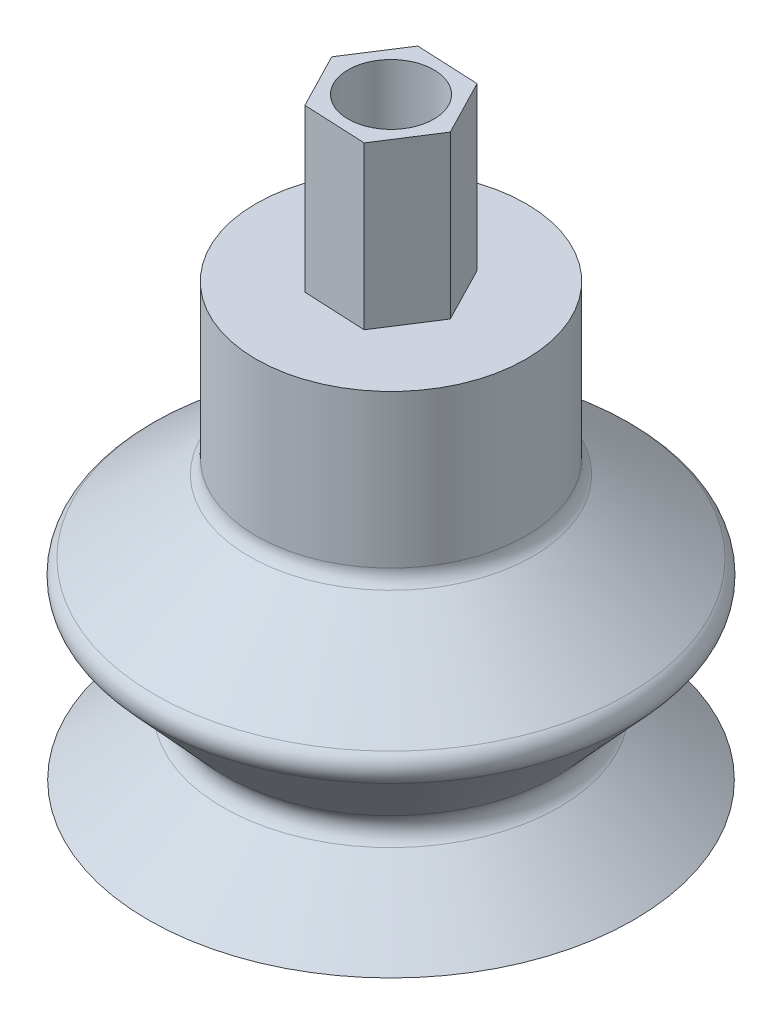
from build123d import *

# Parameters (mm, degrees)
CASCA1_T                 = -0.9
RESSALTO_EXTRUS_O1_DEPTH = 9
FILETE1_R                = 1
ESBO_O3_R                = 2.38125
CORTE_EXTRUS_O1_DEPTH    = 34.0000001
ESQUISSE1_R              = 6.732461852
ENL_V_MAT_EXTRU_1_DEPTH  = 9


with BuildPart() as part:
    # Esboço1 → Revolução1 (revolve)
    with BuildSketch(Plane.XY):
        Polygon((0, 0), (13.5, 0), (8.5, 4), (14, 10), (7.5, 15), (7.5, 24), (0, 24), align=None)
    revolve(axis=Axis((0, 24, 0), (0, -1, 0)))

    # Casca1
    casca1_openings = [part.faces().sort_by_distance(p)[0] for p in [
        (-13.5, 0, 0),
    ]]
    offset(amount=CASCA1_T, openings=casca1_openings, kind=Kind.INTERSECTION)

    # Esboço2 → Ressalto-extrusão1 (add)
    with BuildSketch(Plane(origin=(0, 24, 0), x_dir=(1, 0, 0), z_dir=(0, 1, 0))):
        Polygon((2.496763598, 3.885808136), (-2.11682676, 4.105164771), (-4.613590359, 0.219356636), (-2.496763598, -3.885808136), (2.11682676, -4.105164771), (4.613590359, -0.219356636), align=None)
    extrude(amount=RESSALTO_EXTRUS_O1_DEPTH)

    # Filete1
    filete1_edges = [part.edges().sort_by_distance(p)[0] for p in [
        (-7.5, 15, 0),
        (-14, 10, 0),
        (-8.5, 4, 0),
    ]]
    fillet(filete1_edges, radius=FILETE1_R)

    # Esboço3 → Corte-extrusão1 (cut, through all)
    with BuildSketch(Plane(origin=(0, 33, 0), x_dir=(1, 0, 0), z_dir=(0, 1, 0))):
        Circle(ESBO_O3_R)
    extrude(amount=-CORTE_EXTRUS_O1_DEPTH, mode=Mode.SUBTRACT)

    # Esquisse1 → Enlèv. mat.-Extru.1 (cut)
    with BuildSketch(Plane(origin=(0, 33, 0), x_dir=(1, 0, 0), z_dir=(0, 1, 0))):
        Circle(ESQUISSE1_R)
        Polygon((1.58762007, -3.078873578), (3.460192769, -0.164517477), (1.872572699, 2.914356102), (-1.58762007, 3.078873578), (-3.460192769, 0.164517477), (-1.872572699, -2.914356102), align=None, mode=Mode.SUBTRACT)
    extrude(amount=-ENL_V_MAT_EXTRU_1_DEPTH, mode=Mode.SUBTRACT)


solid = part.part
